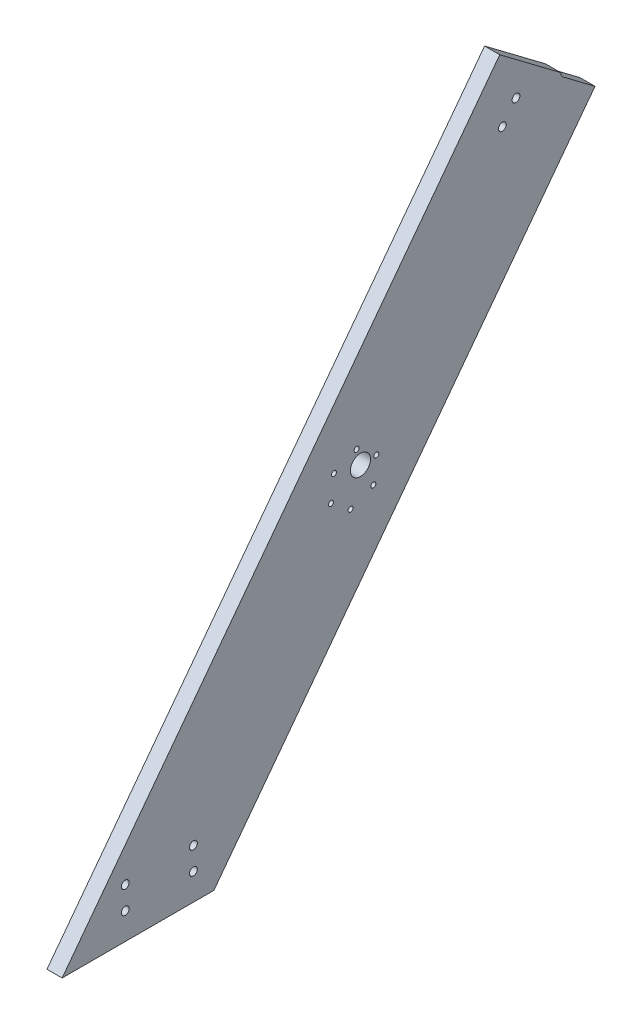
from build123d import *

# Parameters (mm, degrees)
BOSS_EXTRUDE1_DEPTH = 9.525
CUT_EXTRUDE1_DEPTH  = 10.525
SKETCH3_R           = 6.35
SKETCH3_R_2         = 1.5875
CUT_EXTRUDE2_DEPTH  = 10.525
SKETCH4_R           = 2.4638
CUT_EXTRUDE3_DEPTH  = 10.525


with BuildPart() as part:
    # Sketch1 → Boss-Extrude1 (new body)
    with BuildSketch(Plane(origin=(0, 0, 0), x_dir=(0, 0, -1), z_dir=(1, 0, 0))):
        Polygon((0, 0), (275.149828585, 365.136155194), (336.005854451, 319.277850429), (95.412737152, 0), align=None)
    extrude(amount=BOSS_EXTRUDE1_DEPTH)

    # Sketch2 → Cut-Extrude1 (cut, through all)
    with BuildSketch(Plane(origin=(9.525, 0, 0), x_dir=(0, 0, -1), z_dir=(1, 0, 0))):
        with BuildLine():
            Line((335.050473101, 318.010016557), (314.765131146, 333.296118145))
            ThreePointArc((314.765131146, 333.296118145), (313.753290935, 334.591214557), (313.524559813, 336.218721055))
            Line((313.524559813, 336.218721055), (336.005854451, 319.277850429))
            Line((336.005854451, 319.277850429), (335.050473101, 318.010016557))
        make_face()
    extrude(amount=-CUT_EXTRUDE1_DEPTH, mode=Mode.SUBTRACT)

    # Sketch3 → Cut-Extrude2 (cut, through all)
    with BuildSketch(Plane(origin=(9.525, 0, 0), x_dir=(0, 0, -1), z_dir=(1, 0, 0))):
        with Locations((187.569137258, 185.604162917)):
            Circle(SKETCH3_R)
        with Locations((195.663087406, 170.599745201)):
            Circle(SKETCH3_R_2)
        with Locations((181.400785207, 164.545757096)):
            Circle(SKETCH3_R_2)
        with Locations((169.026726614, 173.870279065)):
            Circle(SKETCH3_R_2)
        with Locations((170.914970221, 189.248789139)):
            Circle(SKETCH3_R_2)
        with Locations((185.17727242, 195.302777243)):
            Circle(SKETCH3_R_2)
        with Locations((197.551331013, 185.978255275)):
            Circle(SKETCH3_R_2)
    extrude(amount=-CUT_EXTRUDE2_DEPTH, mode=Mode.SUBTRACT)

    # Sketch4 → Cut-Extrude3 (cut, through all)
    with BuildSketch(Plane(origin=(9.525, 0, 0), x_dir=(0, 0, -1), z_dir=(1, 0, 0))):
        with Locations((285.346343492, 336.461727915)):
            Circle(SKETCH4_R)
        with Locations((276.786126603, 325.10193642)):
            Circle(SKETCH4_R)
        with Locations((39.6875, 30.988)):
            Circle(SKETCH4_R)
        with Locations((39.6875, 16.764)):
            Circle(SKETCH4_R)
        with Locations((82.55, 30.988)):
            Circle(SKETCH4_R)
        with Locations((82.55, 16.764)):
            Circle(SKETCH4_R)
    extrude(amount=-CUT_EXTRUDE3_DEPTH, mode=Mode.SUBTRACT)


solid = part.part
